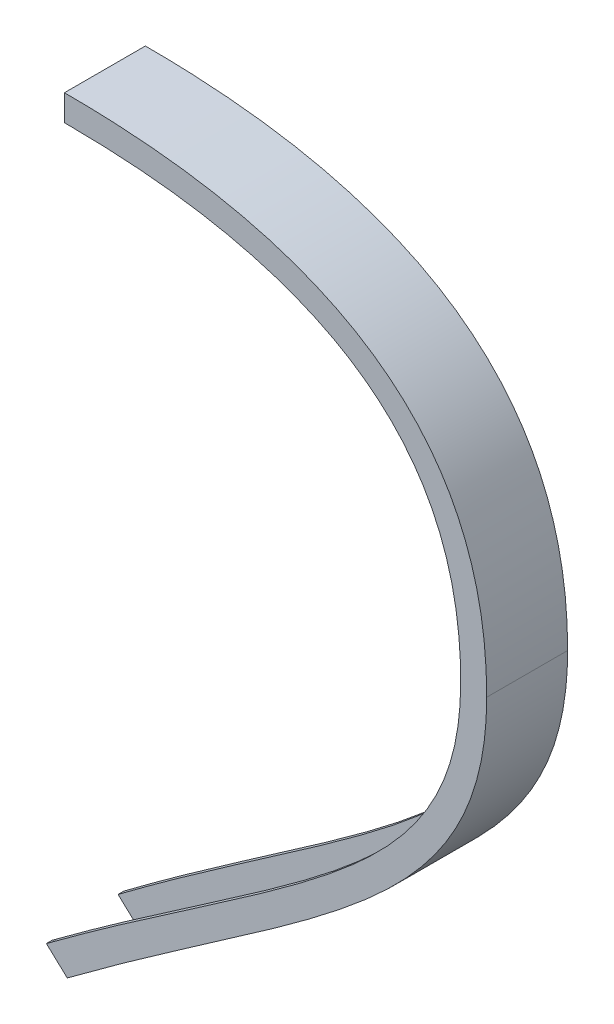
from build123d import *

# Parameters (mm, degrees)
BOSS_EXTRU_2_DEPTH = 2
BOSS_EXTRU_3_START = -2
BOSS_EXTRU_3_DEPTH = 26
BOSS_EXTRU_4_DEPTH = 2


with BuildPart() as part:
    # Esquisse1 → Boss.-Extru.2 (new body)
    with BuildSketch(Plane.XY):
        with BuildLine():
            Line((-0.00400884, 119.040016289), (-0.00400884, 109.040016289))
            add(Edge.make_bspline(
                [(135.094881688, 12.347656768), (135.094881688, 13.413901205), (135.071208206, 15.561386013), (134.929810594, 19.734818404), (134.577965377, 24.807384894), (133.879838594, 30.638399661), (132.586934474, 38.083732214), (130.303010899, 46.775838335), (126.522895447, 56.26542587), (121.714013565, 64.87582069), (113.906223439, 75.274579224), (101.414591155, 86.411112386), (84.858728164, 95.192064474), (69.027521057, 100.70017665), (55.854146224, 104.041872862), (41.378624621, 106.567746277), (28.23572446, 107.974828147), (17.076606526, 108.67368115), (8.962691216, 108.96245631), (3.196225492, 109.035828431), (0.377060546, 109.040016289), (-0.00400884, 109.040016289)],
                knots=[0.497645186, 0.497645186, 0.497645186, 0.497645186, 0.49775367, 0.497862155, 0.498079123, 0.498296092, 0.498513061, 0.498946998, 0.499380936, 0.499814874, 0.500248811, 0.501116686, 0.501984561, 0.502418499, 0.502852437, 0.503286374, 0.503720312, 0.50393728, 0.504154249, 0.50432818, 0.504355301, 0.504355301, 0.504355301, 0.504355301], degree=3))
            add(Edge.make_bspline(
                [(-7.449810705, -136.903796747), (-7.10889508, -136.648659025), (-5.729139825, -135.616252852), (-2.963715196, -133.550423631), (4.889274506, -127.747683962), (16.846101009, -119.129451608), (32.071653761, -108.457658237), (46.502334017, -98.474358922), (60.065937573, -89.050300935), (76.895347004, -77.063866417), (95.393165507, -62.85955821), (110.033873571, -48.95682606), (119.259236565, -37.611895851), (124.934715012, -28.873289935), (129.38275296, -19.749589671), (132.080400116, -11.653928753), (133.622437355, -4.760222546), (134.46296061, 0.646964432), (134.891739077, 5.381679919), (135.065530665, 9.303607794), (135.094881688, 11.339077189), (135.094881688, 12.347656768)],
                knots=[0.348198397, 0.348198397, 0.348198397, 0.348198397, 0.350826165, 0.35882463, 0.369335702, 0.411379988, 0.453424275, 0.495468561, 0.537512848, 0.579557134, 0.663645708, 0.747734281, 0.789778567, 0.831822854, 0.87386714, 0.915911427, 0.93693357, 0.957955713, 0.978977857, 0.989488928, 1, 1, 1, 1], degree=3))
            Line((-7.449810705, -136.903796747), (-0.00400884, -143.821780254))
            add(Edge.make_bspline(
                [(-0.00400884, -143.821780254), (84.073321163, -80.899177556), (145.094881689, -56.542131568), (145.094881688, 12.347656767)],
                knots=[0.351934339, 0.351934339, 0.351934339, 0.351934339, 1, 1, 1, 1], degree=3))
            add(Edge.make_bspline(
                [(145.094881688, 12.347656767), (145.094881688, 119.040016289), (-0.00400884, 119.040016289)],
                knots=[0, 0, 0, 1, 1, 1], degree=2))
        make_face()
    extrude(amount=BOSS_EXTRU_2_DEPTH)

    # Esquisse2 → Boss.-Extru.3 (add)
    with BuildSketch(Plane.XY.offset(2).offset(BOSS_EXTRU_3_START)):
        with BuildLine():
            Line((-0.004008825, 120.040016289), (-0.004008826, 119.040016289))
            add(Edge.make_bspline(
                [(145.094881688, 12.347656779), (145.09488168, 119.040016284), (-0.004008826, 119.040016289)],
                knots=[0, 0, 0, 1, 1, 1], degree=2))
            add(Edge.make_bspline(
                [(-0.00400884, -143.821780254), (84.073321163, -80.899177556), (145.094881689, -56.542131568), (145.094881688, 12.347656779)],
                knots=[0.351934339, 0.351934339, 0.351934339, 0.351934339, 1, 1, 1, 1], degree=3))
            Line((-0.00400884, -143.821780254), (0.974938317, -144.731331758))
            add(Edge.make_bspline(
                [(0.974938317, -144.731331758), (1.940347306, -144.009490017), (4.21694405, -142.313603561), (9.069225919, -138.732599504), (15.486781125, -134.06221379), (23.035718298, -128.658372426), (32.89561739, -121.694049694), (44.81515406, -113.404531475), (58.415951602, -103.998408935), (71.258842891, -95.010378812), (87.298930593, -83.418573034), (105.179437585, -69.354076661), (119.797375804, -55.02176587), (129.301227667, -42.891938136), (135.271714019, -33.338868533), (140.021533003, -23.209667681), (142.910061689, -14.192327822), (144.54940778, -6.575429809), (145.436220501, -0.648844125), (145.883993765, 4.48605166), (146.064181974, 8.705544543), (146.094392663, 10.876345952), (146.094392664, 11.95427261)],
                knots=[0.352912923, 0.352912923, 0.352912923, 0.352912923, 0.360370171, 0.370523026, 0.390828735, 0.411134444, 0.431440152, 0.47205157, 0.512662988, 0.553274405, 0.593885823, 0.675108659, 0.756331494, 0.796942912, 0.837554329, 0.878165747, 0.918777165, 0.939082873, 0.959388582, 0.979694291, 0.989847146, 1, 1, 1, 1], degree=3))
            add(Edge.make_bspline(
                [(146.094392664, 11.95427261), (146.097169698, 13.072010325), (146.078781877, 15.319946132), (145.945806495, 19.715306464), (145.599271174, 25.090276491), (144.894482198, 31.327678025), (143.568987818, 39.368274841), (141.187761716, 48.897461146), (137.168556158, 59.495541245), (131.986355052, 69.250882021), (123.527763641, 81.126183408), (110.059371985, 93.832155871), (92.76947067, 103.671463097), (76.660196542, 109.831050786), (63.440632963, 113.59775321), (49.083840319, 116.514014852), (36.172205395, 118.237343204), (25.273213662, 119.192706074), (16.815980973, 119.69774819), (9.525747125, 119.942490272), (3.969994561, 120.026549051), (1.268546425, 120.039639283), (0.07918291, 120.040016289), (-0.004008825, 120.040016289)],
                knots=[0.497632905, 0.497632905, 0.497632905, 0.497632905, 0.497738302, 0.497843699, 0.498054494, 0.498265288, 0.498476082, 0.498897671, 0.49931926, 0.499740849, 0.500162438, 0.501005615, 0.501848793, 0.502270382, 0.502691971, 0.50311356, 0.503535149, 0.503745943, 0.503956737, 0.504167532, 0.504272929, 0.504349545, 0.504355301, 0.504355301, 0.504355301, 0.504355301], degree=3))
        make_face()
    extrude(amount=BOSS_EXTRU_3_DEPTH)

    # Esquisse3 → Boss.-Extru.4 (add)
    with BuildSketch(Plane.XY.offset(26)):
        with BuildLine():
            Line((-6.255730586, -138.013230858), (0.974938317, -144.731331758))
            add(Edge.make_bspline(
                [(0.974938317, -144.731331758), (1.940347306, -144.009490017), (4.21694405, -142.313603561), (9.069225919, -138.732599504), (15.486781125, -134.06221379), (23.035718298, -128.658372426), (32.89561739, -121.694049694), (44.81515406, -113.404531475), (58.415951602, -103.998408935), (71.258842891, -95.010378812), (87.298930593, -83.418573034), (105.179437585, -69.354076661), (119.797375804, -55.02176587), (129.301227667, -42.891938136), (135.271714019, -33.338868533), (140.021533003, -23.209667681), (142.910061689, -14.192327822), (144.54940778, -6.575429809), (145.436220501, -0.648844125), (145.883993765, 4.48605166), (146.064181974, 8.705544543), (146.094392663, 10.876345952), (146.094392664, 11.95427261)],
                knots=[0.352912923, 0.352912923, 0.352912923, 0.352912923, 0.360370171, 0.370523026, 0.390828735, 0.411134444, 0.431440152, 0.47205157, 0.512662988, 0.553274405, 0.593885823, 0.675108659, 0.756331494, 0.796942912, 0.837554329, 0.878165747, 0.918777165, 0.939082873, 0.959388582, 0.979694291, 0.989847146, 1, 1, 1, 1], degree=3))
            add(Edge.make_bspline(
                [(146.094392664, 11.95427261), (146.097169698, 13.072010325), (146.078781877, 15.319946132), (145.945806495, 19.715306464), (145.599271174, 25.090276491), (144.894482198, 31.327678025), (143.568987818, 39.368274841), (141.187761716, 48.897461146), (137.168556158, 59.495541245), (131.986355052, 69.250882021), (123.527763641, 81.126183408), (110.059371985, 93.832155871), (92.76947067, 103.671463097), (76.660196542, 109.831050786), (63.440632963, 113.59775321), (49.083840319, 116.514014852), (36.172205395, 118.237343204), (25.273213662, 119.192706074), (16.815980973, 119.69774819), (9.525747125, 119.942490272), (3.969994561, 120.026549051), (1.268546425, 120.039639283), (0.07918291, 120.040016289), (-0.004008825, 120.040016289)],
                knots=[0.497632905, 0.497632905, 0.497632905, 0.497632905, 0.497738302, 0.497843699, 0.498054494, 0.498265288, 0.498476082, 0.498897671, 0.49931926, 0.499740849, 0.500162438, 0.501005615, 0.501848793, 0.502270382, 0.502691971, 0.50311356, 0.503535149, 0.503745943, 0.503956737, 0.504167532, 0.504272929, 0.504349545, 0.504355301, 0.504355301, 0.504355301, 0.504355301], degree=3))
            Line((-0.004008825, 120.040016289), (-0.004008837, 111.034812981))
            Line((-0.004008837, 111.034812981), (1.995991163, 111.034812981))
            add(Edge.make_bspline(
                [(1.995991163, 111.034812981), (3.449262421, 111.027220593), (6.373451501, 110.994919277), (12.078992886, 110.86307951), (19.041360742, 110.572013465), (27.096560383, 110.021948285), (37.44407538, 109.022298227), (49.636750503, 107.277037509), (63.077298444, 104.403154728), (75.325820827, 100.767072473), (90.070257503, 94.929738917), (105.558045333, 85.838284977), (117.326821816, 74.44364635), (124.692400635, 63.871078074), (129.218597962, 55.159425743), (132.755299467, 45.619839598), (134.868553088, 36.942511152), (136.048603344, 29.554857683), (136.673045155, 23.780276366), (137.042498844, 17.801325721), (137.094881688, 13.614675878), (137.094881688, 11.546026453)],
                knots=[0.497925446, 0.497925446, 0.497925446, 0.497925446, 0.498029976, 0.498134506, 0.498343566, 0.498552626, 0.498761687, 0.499179807, 0.499597928, 0.500016048, 0.500434169, 0.50127041, 0.502106651, 0.502524771, 0.502942892, 0.503361012, 0.503779133, 0.503988193, 0.504197253, 0.504406314, 0.504615374, 0.504615374, 0.504615374, 0.504615374], degree=3))
            add(Edge.make_bspline(
                [(137.094881688, 11.546026453), (137.090459851, 10.56000328), (137.053988144, 8.572176445), (136.873136382, 4.726528145), (136.448066581, 0.078634705), (135.629544709, -5.251256128), (134.138536999, -12.059875265), (131.543268898, -20.076285021), (127.287184822, -29.098949454), (121.889707547, -37.700731392), (113.169191271, -48.794863494), (99.423443834, -62.24312359), (82.136049919, -75.772908771), (66.415298449, -87.051616014), (53.742936395, -95.846083964), (40.251923361, -105.089213893), (28.379063236, -113.260921468), (18.534046888, -120.138514542), (10.986640564, -125.480414397), (4.561562429, -130.101377496), (-0.648471776, -133.898956426), (-3.289933492, -135.846791526), (-4.603005712, -136.818779696)],
                knots=[0.327291415, 0.327291415, 0.327291415, 0.327291415, 0.337398931, 0.347506447, 0.367721479, 0.387936511, 0.408151543, 0.448581608, 0.489011672, 0.529441736, 0.5698718, 0.650731928, 0.731592057, 0.772022121, 0.812452185, 0.852882249, 0.893312313, 0.913527345, 0.933742378, 0.95395741, 0.964064926, 0.974172442, 0.974172442, 0.974172442, 0.974172442], degree=3))
            Line((-4.603005712, -136.818779696), (-6.255730586, -138.013230858))
        make_face()
    extrude(amount=BOSS_EXTRU_4_DEPTH)


solid = part.part
